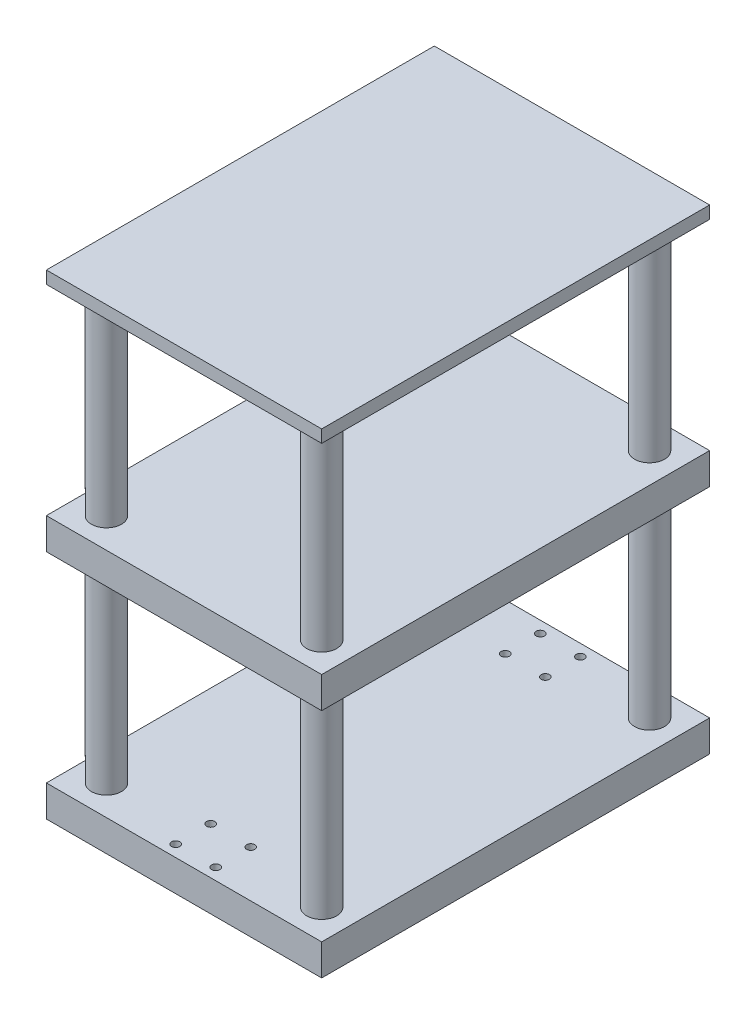
from build123d import *

# Parameters (mm, degrees)
SKETCH1_W                           = 110
SKETCH1_H                           = 155
BOSS_EXTRUDE1_DEPTH                 = 12.5
SKETCH2_R                           = 6
BOSS_EXTRUDE2_DEPTH                 = 80
MIRROR2_COPY_1_SKETCH_R             = 6
MIRROR2_COPY_1_DEPTH                = 80
LPATTERN1_COUNT                     = 2
LPATTERN1_PITCH                     = 92.5
F_3_3_3_3_DIAMETER_HOLE1_AT_2_COUNT = 2
F_3_3_3_3_DIAMETER_HOLE1_AT_2_PITCH = 16
LPATTERN3_COUNT                     = 2
LPATTERN3_PITCH                     = 14
SKETCH7_W                           = 110
SKETCH7_H                           = 155
BOSS_EXTRUDE3_DEPTH                 = 5


with BuildPart() as part:
    # Sketch1 → Boss-Extrude1 (new body)
    with BuildSketch(Plane(origin=(0, 0, 0), x_dir=(1, 0, 0), z_dir=(0, 1, 0))):
        Rectangle(SKETCH1_W, SKETCH1_H)
    extrude(amount=BOSS_EXTRUDE1_DEPTH)

    # Sketch2 → Boss-Extrude2 (add)
    with BuildSketch(Plane(origin=(0, 12.5, 0), x_dir=(1, 0, 0), z_dir=(0, 1, 0))):
        with Locations((-43, 65.5)):
            Circle(SKETCH2_R)
    boss_extrude2 = extrude(amount=BOSS_EXTRUDE2_DEPTH)

    # Mirror1: Boss-Extrude2 across plane
    add(boss_extrude2.mirror(Plane.XY))

    # Mirror2: Boss-Extrude2 across plane
    add(boss_extrude2.mirror(Plane(origin=(0, 0, 0), x_dir=(0, 0, 1), z_dir=(1, 0, 0))))

    # Mirror2 copy 1 sketch → Mirror2 copy 1 (add)
    with BuildSketch(Plane(origin=(0, 12.5, 0), x_dir=(-1, 0, 0), z_dir=(0, 1, 0))):
        with Locations((-43, 65.5)):
            Circle(MIRROR2_COPY_1_SKETCH_R)
    extrude(amount=MIRROR2_COPY_1_DEPTH)


with BuildPart() as lpattern1_1:
    # LPattern1: pattern copy
    add(part.part.moved(Location(Vector(0, -1, 0) * (1 * LPATTERN1_PITCH))))

    # Sketch6 → Ø3.3 (3.3) Diameter Hole1 (revolve, cut)
    with BuildSketch(Plane(origin=(8, -92.5, 72.85), x_dir=(0, 0, -1), z_dir=(1, 0, 0))):
        Polygon((0, 0), (0, 20.991420021), (1.65, 20), (1.65, 0), align=None)
    f_3_3_3_3_diameter_hole1 = revolve(axis=Axis((8, -98.85, 72.85), (0, 1, 0)), mode=Mode.SUBTRACT)

    # Ø3.3 (3.3) Diameter Hole1 at 2: Ø3.3 (3.3) Diameter Hole1 ×2
    with Locations(*[(-i * F_3_3_3_3_DIAMETER_HOLE1_AT_2_PITCH, 0, 0) for i in range(1, F_3_3_3_3_DIAMETER_HOLE1_AT_2_COUNT)]):
        add(f_3_3_3_3_diameter_hole1, mode=Mode.SUBTRACT)

    # LPattern3: Ø3.3 (3.3) Diameter Hole1 ×2
    with Locations(*[(0, 0, -i * LPATTERN3_PITCH) for i in range(1, LPATTERN3_COUNT)]):
        add(f_3_3_3_3_diameter_hole1, mode=Mode.SUBTRACT)

    # LPattern3 copy 1 sketch → LPattern3 copy 1 (revolve, cut)
    with BuildSketch(Plane(origin=(-8, -92.5, 58.85), x_dir=(0, 0, -1), z_dir=(1, 0, 0))):
        Polygon((0, 0), (0, 20.991420021), (1.65, 20), (1.65, 0), align=None)
    revolve(axis=Axis((-8, -98.85, 58.85), (0, 1, 0)), mode=Mode.SUBTRACT)

    # Mirror3: Ø3.3 (3.3) Diameter Hole1 across plane
    add(f_3_3_3_3_diameter_hole1.mirror(Plane.XY), mode=Mode.SUBTRACT)

    # Mirror3 copy 1 sketch → Mirror3 copy 1 (revolve, cut)
    with BuildSketch(Plane(origin=(8, -92.5, -58.85), x_dir=(0, 0, 1), z_dir=(1, 0, 0))):
        Polygon((0, 0), (0, -20.991420021), (1.65, -20), (1.65, 0), align=None)
    revolve(axis=Axis((8, -98.85, -58.85), (0, -1, 0)), mode=Mode.SUBTRACT)

    # Mirror3 copy 2 sketch → Mirror3 copy 2 (revolve, cut)
    with BuildSketch(Plane(origin=(-8, -92.5, -58.85), x_dir=(0, 0, 1), z_dir=(1, 0, 0))):
        Polygon((0, 0), (0, -20.991420021), (1.65, -20), (1.65, 0), align=None)
    revolve(axis=Axis((-8, -98.85, -58.85), (0, -1, 0)), mode=Mode.SUBTRACT)

    # Mirror3 copy 3 sketch → Mirror3 copy 3 (revolve, cut)
    with BuildSketch(Plane(origin=(-8, -92.5, -72.85), x_dir=(0, 0, 1), z_dir=(1, 0, 0))):
        Polygon((0, 0), (0, -20.991420021), (1.65, -20), (1.65, 0), align=None)
    revolve(axis=Axis((-8, -98.85, -72.85), (0, -1, 0)), mode=Mode.SUBTRACT)


with BuildPart() as part_1:
    add(part.part)

    # Sketch7 → Boss-Extrude3 (add)
    with BuildSketch(Plane(origin=(0, 92.5, 0), x_dir=(1, 0, 0), z_dir=(0, 1, 0))):
        Rectangle(SKETCH7_W, SKETCH7_H)
    extrude(amount=BOSS_EXTRUDE3_DEPTH)


solid = Compound([lpattern1_1.part, part_1.part])
